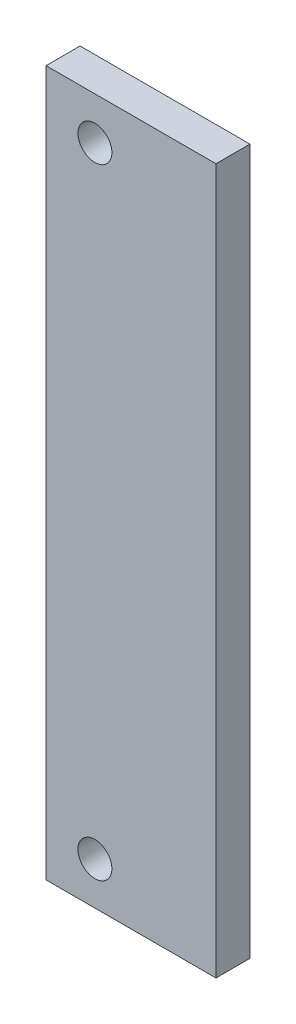
from build123d import *

# Parameters (mm, degrees)
SKETCH1_W           = 40
SKETCH1_H           = 166
BOSS_EXTRUDE1_DEPTH = 4
SKETCH2_R           = 4
CUT_EXTRUDE1_DEPTH  = 9


with BuildPart() as part:
    # Sketch1 → Boss-Extrude1 (new body, symmetric)
    with BuildSketch(Plane.XY):
        Rectangle(SKETCH1_W, SKETCH1_H)
    extrude(amount=BOSS_EXTRUDE1_DEPTH, both=True)

    # Sketch2 → Cut-Extrude1 (cut, through all)
    with BuildSketch(Plane.XY.offset(4)):
        with Locations((-8.5, 73)):
            Circle(SKETCH2_R)
        with Locations((-8.5, -73)):
            Circle(SKETCH2_R)
    extrude(amount=-CUT_EXTRUDE1_DEPTH, mode=Mode.SUBTRACT)


solid = part.part
